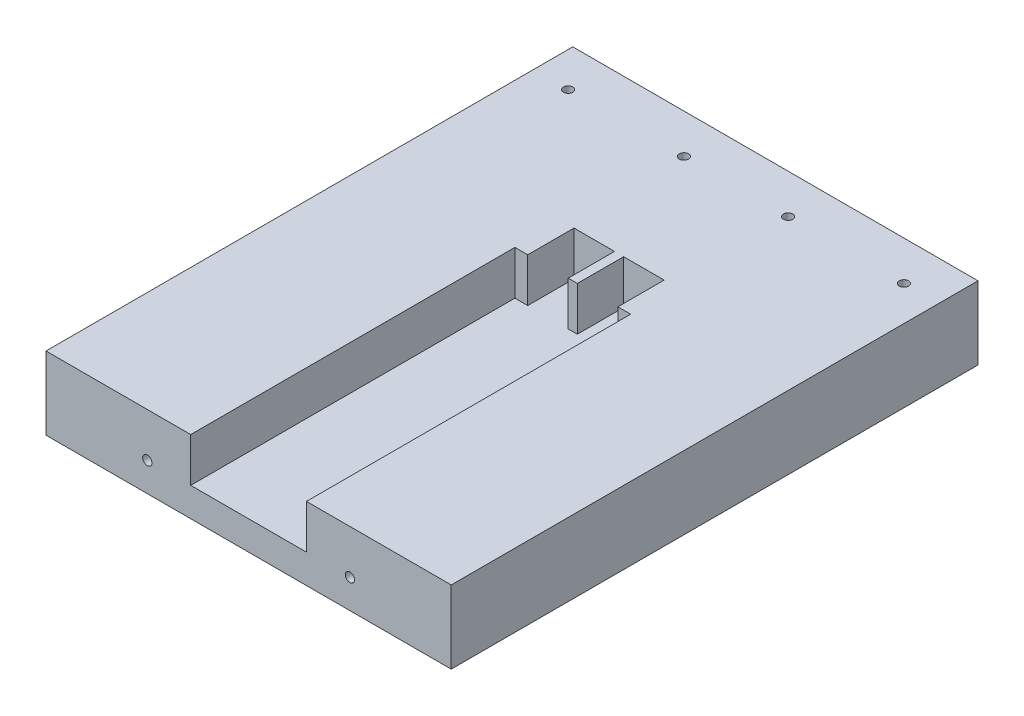
from build123d import *

# Parameters (mm, degrees)
BOSS_EXTRUDE2_DEPTH = 16.002
BOSS_EXTRUDE3_DEPTH = 6.35
SKETCH1_7_W         = 8.89
SKETCH1_7_H         = 10.16
BOSS_EXTRUDE4_DEPTH = 6.35
SKETCH4_R           = 1.016
CUT_EXTRUDE2_DEPTH  = 147.682306036
SKETCH5_R           = 1.016
CUT_EXTRUDE3_DEPTH  = 12.7


with BuildPart() as part:
    # Sketch1 → Boss-Extrude2 (new body)
    with BuildSketch(Plane(origin=(0, 0, 0), x_dir=(1, 0, 0), z_dir=(0, 1, 0))):
        Polygon((0, 115.57), (0, 0), (31.75, 0), (31.75, 71.12), (34.56, 71.12), (34.56, 81.28), (43.45, 81.28), (43.45, 71.12), (45.45, 71.12), (45.45, 81.28), (54.34, 81.28), (54.34, 71.12), (57.15, 71.12), (57.15, 0), (88.9, 0), (88.9, 115.57), align=None)
    extrude(amount=BOSS_EXTRUDE2_DEPTH)



with BuildPart() as body_2:
    # Sketch1_6 → Boss-Extrude3 (new body)
    with BuildSketch(Plane(origin=(0, 0, 0), x_dir=(1, 0, 0), z_dir=(0, 1, 0))):
        Polygon((31.75, 71.12), (31.75, 0), (57.15, 0), (57.15, 71.12), (54.34, 71.12), (45.45, 71.12), (43.45, 71.12), (34.56, 71.12), align=None)
    extrude(amount=BOSS_EXTRUDE3_DEPTH)


with BuildPart() as part_1:
    add(part.part)

    add(body_2.part)  # Boss-Extrude4 merges body 2
    # Sketch1_7 → Boss-Extrude4 (add)
    with BuildSketch(Plane(origin=(0, 0, 0), x_dir=(1, 0, 0), z_dir=(0, 1, 0))):
        with Locations((39.005, 76.2)):
            Rectangle(SKETCH1_7_W, SKETCH1_7_H)
        with Locations((49.895, 76.2)):
            Rectangle(SKETCH1_7_W, SKETCH1_7_H)
    extrude(amount=BOSS_EXTRUDE4_DEPTH)

    # Sketch4 → Cut-Extrude2 (cut, through all)
    with BuildSketch(Plane(origin=(0, 16.002, 0), x_dir=(1, 0, 0), z_dir=(0, 1, 0))):
        with Locations((7.62, 106.934)):
            Circle(SKETCH4_R)
        with Locations((33.02, 106.934)):
            Circle(SKETCH4_R)
        with Locations((55.88, 106.934)):
            Circle(SKETCH4_R)
        with Locations((81.28, 106.934)):
            Circle(SKETCH4_R)
    extrude(amount=-CUT_EXTRUDE2_DEPTH, mode=Mode.SUBTRACT)

    # Sketch5 → Cut-Extrude3 (cut)
    with BuildSketch(Plane.XY):
        with Locations((22.225, 6.35)):
            Circle(SKETCH5_R)
        with Locations((66.675, 6.35)):
            Circle(SKETCH5_R)
    extrude(amount=-CUT_EXTRUDE3_DEPTH, mode=Mode.SUBTRACT)


solid = part_1.part
